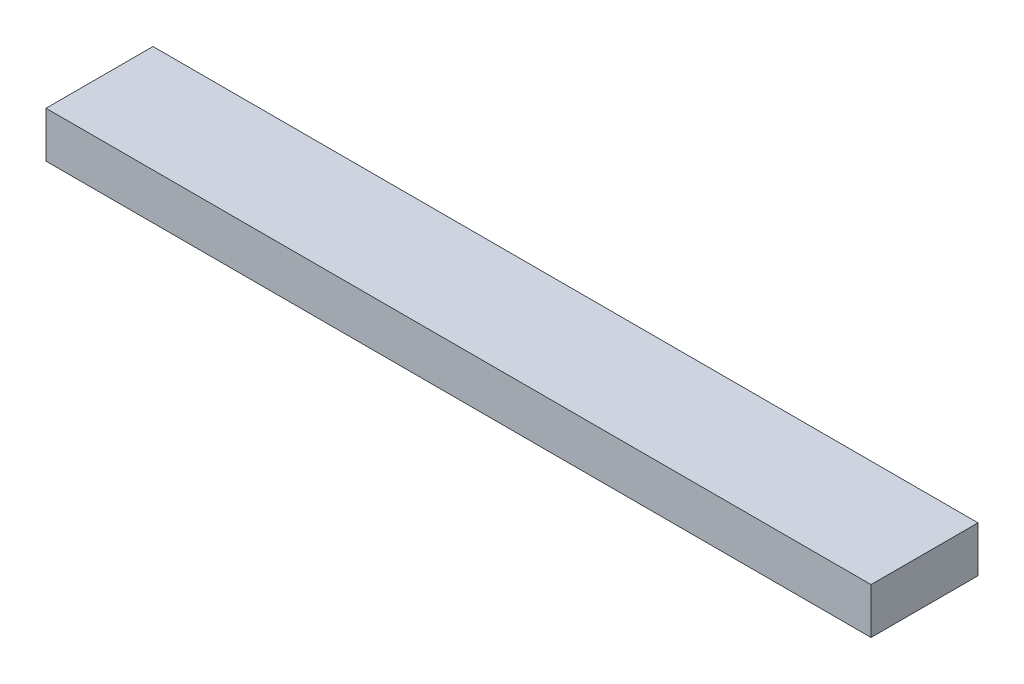
from build123d import *

# Parameters (mm, degrees)
SKETCH1_W           = 685.8
SKETCH1_H           = 88.9
BOSS_EXTRUDE1_DEPTH = 38.1


with BuildPart() as part:
    # Sketch1 → Boss-Extrude1 (new body)
    with BuildSketch(Plane(origin=(0, 0, 0), x_dir=(1, 0, 0), z_dir=(0, 1, 0))):
        with Locations((342.9, 44.45)):
            Rectangle(SKETCH1_W, SKETCH1_H)
    extrude(amount=BOSS_EXTRUDE1_DEPTH)


solid = part.part
